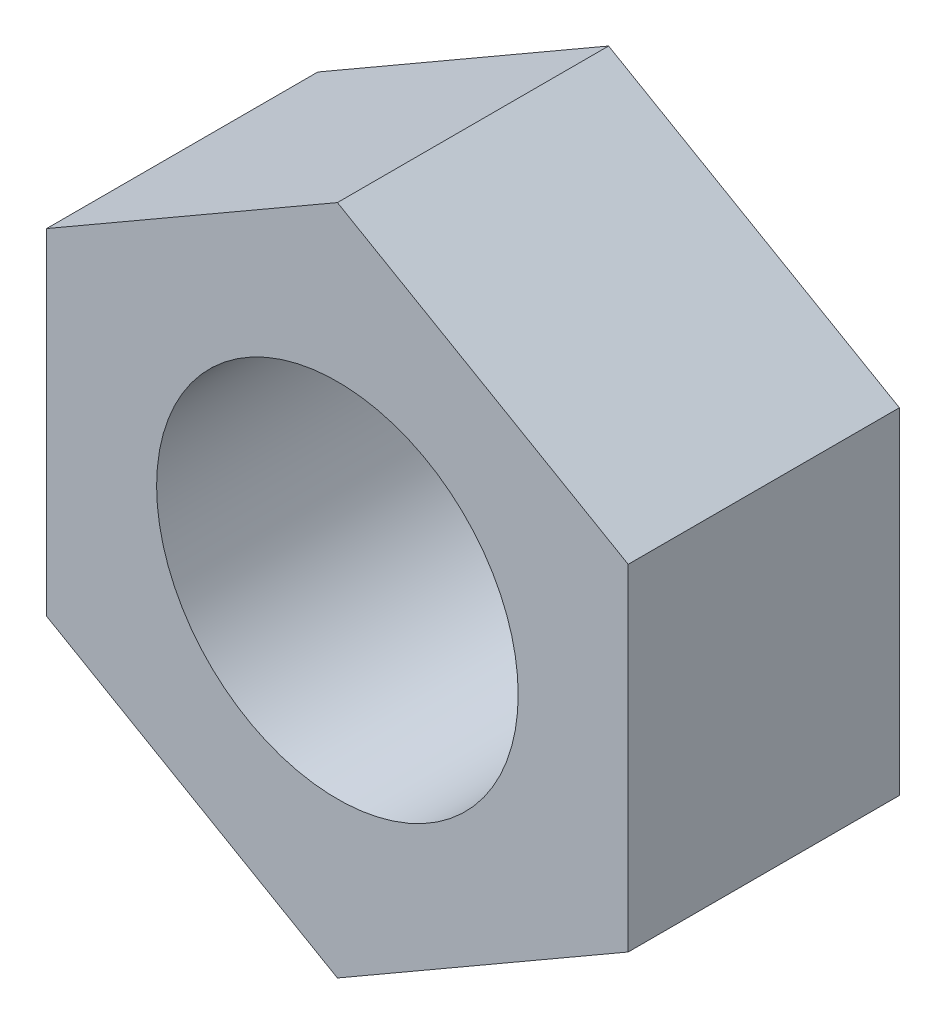
from build123d import *

# Parameters (mm, degrees)
SKETCH1_R           = 6
BOSS_EXTRUDE1_DEPTH = 4.5


with BuildPart() as part:
    # Sketch1 → Boss-Extrude1 (new body, symmetric)
    with BuildSketch(Plane.XY):
        Polygon((0, 11.142860195), (-9.65, 5.571430098), (-9.65, -5.571430098), (0, -11.142860195), (9.65, -5.571430098), (9.65, 5.571430098), align=None)
        Circle(SKETCH1_R, mode=Mode.SUBTRACT)
    extrude(amount=BOSS_EXTRUDE1_DEPTH, both=True)


solid = part.part
